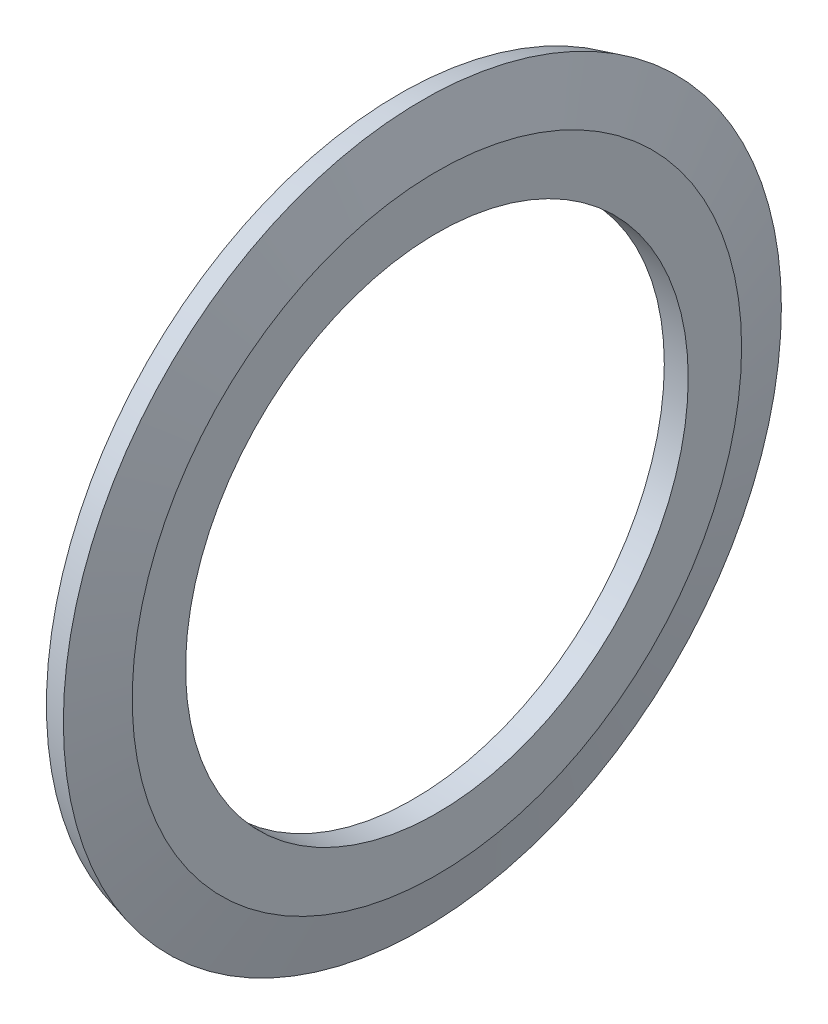
from build123d import *


with BuildPart() as part:
    # Sketch1 → Revolve1 (revolve)
    with BuildSketch(Plane.XY):
        Polygon((1, 10.5), (0, 10.5), (0, 12.598347502), (-0.574170493, 14.741180955), (0.391755333, 15), (1, 12.73), align=None)
    revolve(axis=Axis((1, 0, 0), (-1, 0, 0)))


solid = part.part
